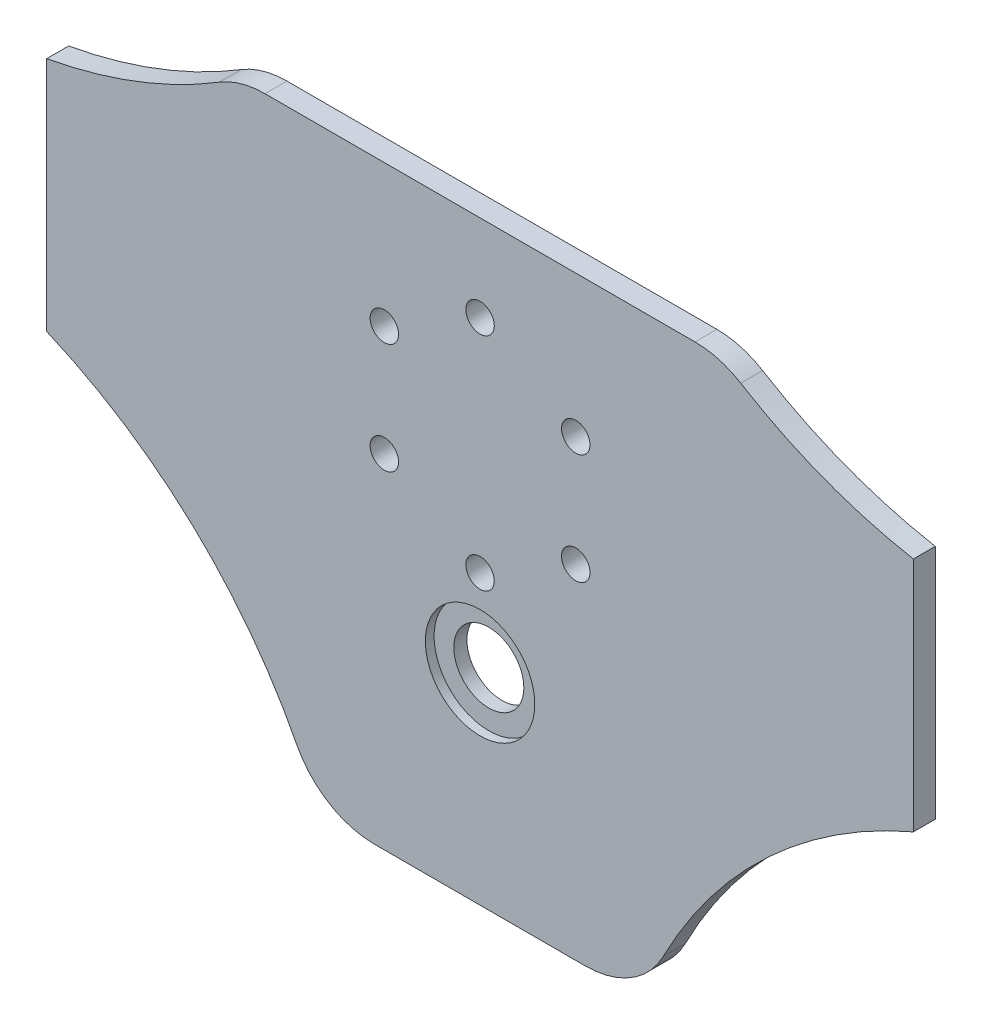
from build123d import *

# Parameters (mm, degrees)
ESBO_O1_R                = 3.25
ESBO_O1_R_2              = 8
RESSALTO_EXTRUS_O1_DEPTH = 5
ESBO_O2_R                = 12.5
ESBO_O2_R_2              = 8
CORTE_EXTRUS_O1_DEPTH    = 2


with BuildPart() as part:
    # Esboço1 → Ressalto-extrusão1 (new body)
    with BuildSketch(Plane.XY):
        with BuildLine():
            Line((-49.119135606, 68), (49.119135606, 68))
            ThreePointArc((49.119135606, 68), (54.543435225, 67.250375935), (59.56111629, 65.057697365))
            ThreePointArc((59.56111629, 65.057697365), (78.583692726, 55.703629757), (99, 50))
            Line((99, 50), (99, -4))
            ThreePointArc((99, -4), (65.800143376, -25.584477196), (41.890064111, -57.150728877))
            ThreePointArc((41.890064111, -57.150728877), (34.522230169, -65.073584532), (24.106246719, -68))
            Line((24.106246719, -68), (-24.106246719, -68))
            ThreePointArc((-24.106246719, -68), (-34.522230169, -65.073584532), (-41.890064111, -57.150728877))
            ThreePointArc((-41.890064111, -57.150728877), (-65.800143376, -25.584477196), (-99, -4))
            Line((-99, -4), (-99, 50))
            ThreePointArc((-99, 50), (-78.583692726, 55.703629757), (-59.56111629, 65.057697365))
            ThreePointArc((-59.56111629, 65.057697365), (-54.543435225, 67.250375935), (-49.119135606, 68))
        make_face()
        with Locations((0, 48.25)):
            Circle(ESBO_O1_R, mode=Mode.SUBTRACT)
        with Locations((21.867141446, 35.625)):
            Circle(ESBO_O1_R, mode=Mode.SUBTRACT)
        with Locations((21.867141446, 10.375)):
            Circle(ESBO_O1_R, mode=Mode.SUBTRACT)
        with Locations((0, -2.25)):
            Circle(ESBO_O1_R, mode=Mode.SUBTRACT)
        with Locations((-21.867141446, 10.375)):
            Circle(ESBO_O1_R, mode=Mode.SUBTRACT)
        with Locations((-21.867141446, 35.625)):
            Circle(ESBO_O1_R, mode=Mode.SUBTRACT)
        with Locations((0, -22)):
            Circle(ESBO_O1_R_2, mode=Mode.SUBTRACT)
    extrude(amount=RESSALTO_EXTRUS_O1_DEPTH)

    # Esboço2 → Corte-extrusão1 (cut)
    with BuildSketch(Plane.XY.offset(5)):
        with Locations((0, -22)):
            Circle(ESBO_O2_R)
        with Locations((0, -22)):
            Circle(ESBO_O2_R_2, mode=Mode.SUBTRACT)
    extrude(amount=-CORTE_EXTRUS_O1_DEPTH, mode=Mode.SUBTRACT)


solid = part.part
